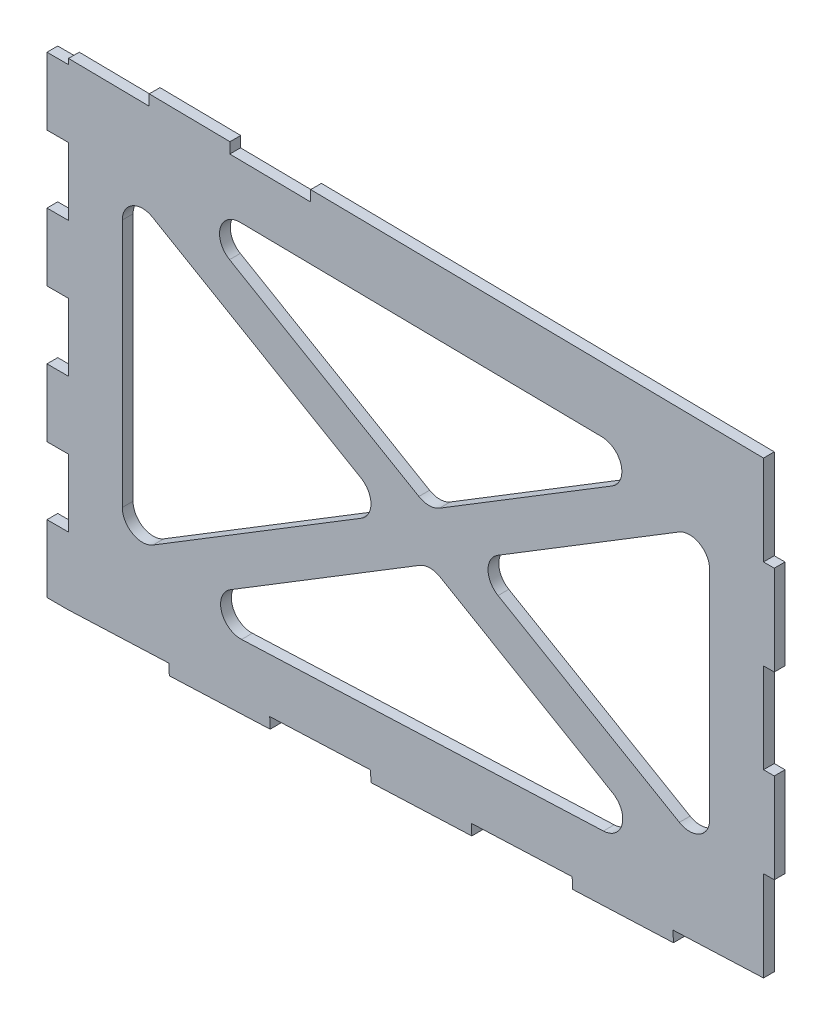
from build123d import *

# Parameters (mm, degrees)
BOSS_EXTRUDE1_DEPTH = 10.16
CUT_EXTRUDE1_DEPTH  = 11.16
SKETCH4_W           = 129.547530324
SKETCH4_H           = 444.037072
CUT_EXTRUDE3_DEPTH  = 11.16
SKETCH5_W           = 10.16
SKETCH5_H           = 84.922739191
CUT_EXTRUDE5_DEPTH  = 11.16
CUT_EXTRUDE6_DEPTH  = 11.16
CUT_EXTRUDE7_DEPTH  = 11.16
FILLET1_R           = 19.05


with BuildPart() as part:
    # Sketch1 → Boss-Extrude1 (new body)
    with BuildSketch(Plane.XY):
        with BuildLine():
            Line((20.32, 73.849956434), (0, 73.849956434))
            Line((0, 73.849956434), (0, 10.164894956))
            Line((0, 10.164894956), (20.32, 10.164894956))
            Line((20.32, 10.164894956), (115.06781826, 14.091181531))
            Line((115.06781826, 14.091181531), (115.488322648, 3.943711998))
            Line((115.488322648, 3.943711998), (210.656645296, 7.887423995))
            Line((210.656645296, 7.887423995), (210.236140908, 18.034893528))
            Line((210.236140908, 18.034893528), (305.404463556, 21.978605526))
            Line((305.404463556, 21.978605526), (305.824967945, 11.831135993))
            Line((305.824967945, 11.831135993), (400.993290593, 15.77484799))
            Line((400.993290593, 15.77484799), (400.572786204, 25.922317523))
            Line((400.572786204, 25.922317523), (495.741108852, 29.866029521))
            Line((495.741108852, 29.866029521), (496.161613241, 19.718559988))
            Line((496.161613241, 19.718559988), (591.329935889, 23.662271985))
            Line((591.329935889, 23.662271985), (590.909431501, 33.809741518))
            Line((590.909431501, 33.809741518), (686.077754149, 37.753453516))
            Line((686.077754149, 37.753453516), (686.498258538, 27.605983983))
            Line((686.498258538, 27.605983983), (781.666581186, 31.54969598))
            Line((781.666581186, 31.54969598), (781.246076797, 41.697165514))
            Line((781.246076797, 41.697165514), (781.246076797, 471.95159927))
            ThreePointArc((781.246076797, 471.95159927), (401.049995582, 500.057636465), (20.32, 519.645386783))
            Line((20.32, 519.645386783), (20.32, 455.960325305))
            Line((20.32, 455.960325305), (0, 455.960325305))
            Line((0, 455.960325305), (0, 392.275263826))
            Line((0, 392.275263826), (20.32, 392.275263826))
            Line((20.32, 392.275263826), (20.32, 328.590202348))
            Line((20.32, 328.590202348), (0, 328.590202348))
            Line((0, 328.590202348), (0, 264.905140869))
            Line((0, 264.905140869), (20.32, 264.905140869))
            Line((20.32, 264.905140869), (20.32, 201.220079391))
            Line((20.32, 201.220079391), (0, 201.220079391))
            Line((0, 201.220079391), (0, 137.535017912))
            Line((0, 137.535017912), (20.32, 137.535017912))
            Line((20.32, 137.535017912), (20.32, 73.849956434))
        make_face()
    extrude(amount=BOSS_EXTRUDE1_DEPTH)

    # Sketch2 → Cut-Extrude1 (cut, through all)
    with BuildSketch(Plane.XY.offset(10.16)):
        Polygon((20.32, 471.23904919), (781.246076797, 460.948390721), (781.246076797, 535.017906983), (20.32, 535.017906983), align=None)
    extrude(amount=-CUT_EXTRUDE1_DEPTH, mode=Mode.SUBTRACT)

    # Sketch4 → Cut-Extrude3 (cut, through all)
    with BuildSketch(Plane(origin=(0, 0, 0), x_dir=(-1, 0, 0), z_dir=(0, 0, -1))):
        with Locations((-751.2720237, 249.624519983)):
            Rectangle(SKETCH4_W, SKETCH4_H)
    extrude(amount=-CUT_EXTRUDE3_DEPTH, mode=Mode.SUBTRACT)

    # Sketch5 → Cut-Extrude5 (cut, through all)
    with BuildSketch(Plane(origin=(0, 0, 0), x_dir=(-1, 0, 0), z_dir=(0, 0, -1))):
        Polygon((-686.498258538, 122.676192707), (-686.498258538, 37.753453516), (-686.077754149, 37.753453516), (-676.338258538, 37.753453516), (-676.338258538, 122.676192707), align=None)
        with Locations((-681.418258538, 250.060301493)):
            Rectangle(SKETCH5_W, SKETCH5_H)
        Polygon((-686.498258538, 462.229747042), (-686.498258538, 377.444410279), (-676.338258538, 377.444410279), (-676.338258538, 462.367149469), align=None)
        Polygon((-676.338258538, 37.349855295), (-686.077754149, 37.753453516), (-686.498258538, 27.605983983), (-686.498258538, 26.157835014), (-676.338258538, 26.157835014), align=None)
        Polygon((-686.077754149, 37.753453516), (-686.498258538, 37.753453516), (-686.498258538, 27.605983983), align=None)
        Polygon((-676.338258538, 37.753453516), (-686.077754149, 37.753453516), (-676.338258538, 37.349855295), align=None)
    extrude(amount=-CUT_EXTRUDE5_DEPTH, mode=Mode.SUBTRACT)

    # Sketch9 → Cut-Extrude6 (cut, through all)
    with BuildSketch(Plane(origin=(0, 0, 0), x_dir=(-1, 0, 0), z_dir=(0, 0, -1))):
        Polygon((-20.32, 471.23904919), (-96.513032663, 470.208625209), (-96.375655361, 460.050483081), (-20.32, 461.07904919), align=None)
        Polygon((-172.706065326, 469.178201229), (-172.575642513, 459.019038375), (-248.768675144, 457.988612006), (-248.906065326, 468.147683023), align=None)
    extrude(amount=-CUT_EXTRUDE6_DEPTH, mode=Mode.SUBTRACT)

    # Sketch10 → Cut-Extrude7 (cut, through all)
    with BuildSketch(Plane.XY.offset(10.16)):
        Polygon((323.935601866, 240.017050622), (71.12, 387.534451737), (71.12, 85.442182155), align=None)
        Polygon((589.808964313, 402.575610007), (109.816203442, 409.066965371), (360.851868456, 262.588153871), align=None)
        Polygon((625.538258538, 108.14417143), (625.538258538, 379.763841656), (398.224628495, 240.781222682), align=None)
        Polygon((361.308361904, 218.210119433), (110.294706958, 64.736985613), (590.245383478, 84.62582245), align=None)
    extrude(amount=-CUT_EXTRUDE7_DEPTH, mode=Mode.SUBTRACT)

    # Fillet1
    fillet1_edges = [part.edges().sort_by_distance(p)[0] for p in [
        (398.224628495, 240.781222682, 5.08),
        (625.538258538, 379.763841656, 5.08),
        (625.538258538, 108.14417143, 5.08),
        (109.816203442, 409.066965371, 5.08),
        (589.808964313, 402.575610007, 5.08),
        (360.851868456, 262.588153871, 5.08),
        (361.308361904, 218.210119433, 5.08),
        (590.245383478, 84.62582245, 5.08),
        (110.294706958, 64.736985613, 5.08),
        (71.12, 387.534451737, 5.08),
        (323.935601866, 240.017050622, 5.08),
        (71.12, 85.442182155, 5.08),
    ]]
    fillet(fillet1_edges, radius=FILLET1_R)


solid = part.part
